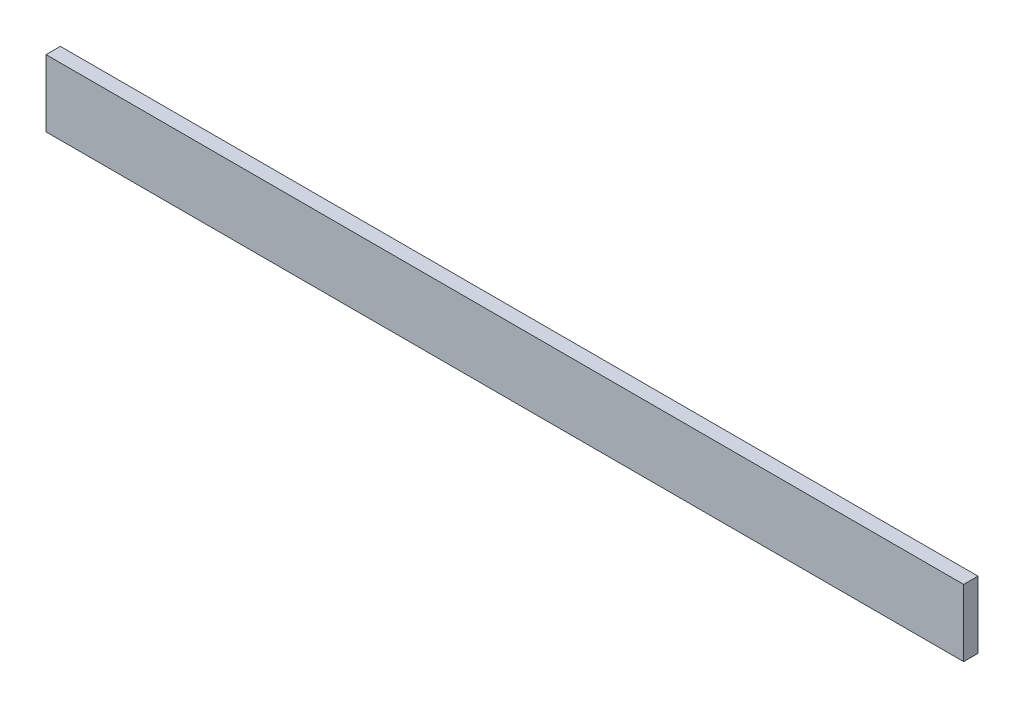
from build123d import *

# Parameters (mm, degrees)
BOSS_EXTRUDE1_DEPTH      = 609.6
BOSS_EXTRUDE1_DEPTH_BACK = 609.6
SKETCH1_W                = 19.05
SKETCH1_H                = 88.9


with BuildPart() as part:
    # Sketch1 → Boss-Extrude1 (new, two sides: drawn at the far end of the back side and taken through both)
    with BuildSketch(Plane(origin=(0, 0, 0), x_dir=(0, 0, -1), z_dir=(1, 0, 0)).offset(-BOSS_EXTRUDE1_DEPTH_BACK)):
        Rectangle(SKETCH1_W, SKETCH1_H)
    extrude(amount=BOSS_EXTRUDE1_DEPTH + BOSS_EXTRUDE1_DEPTH_BACK)


solid = part.part
